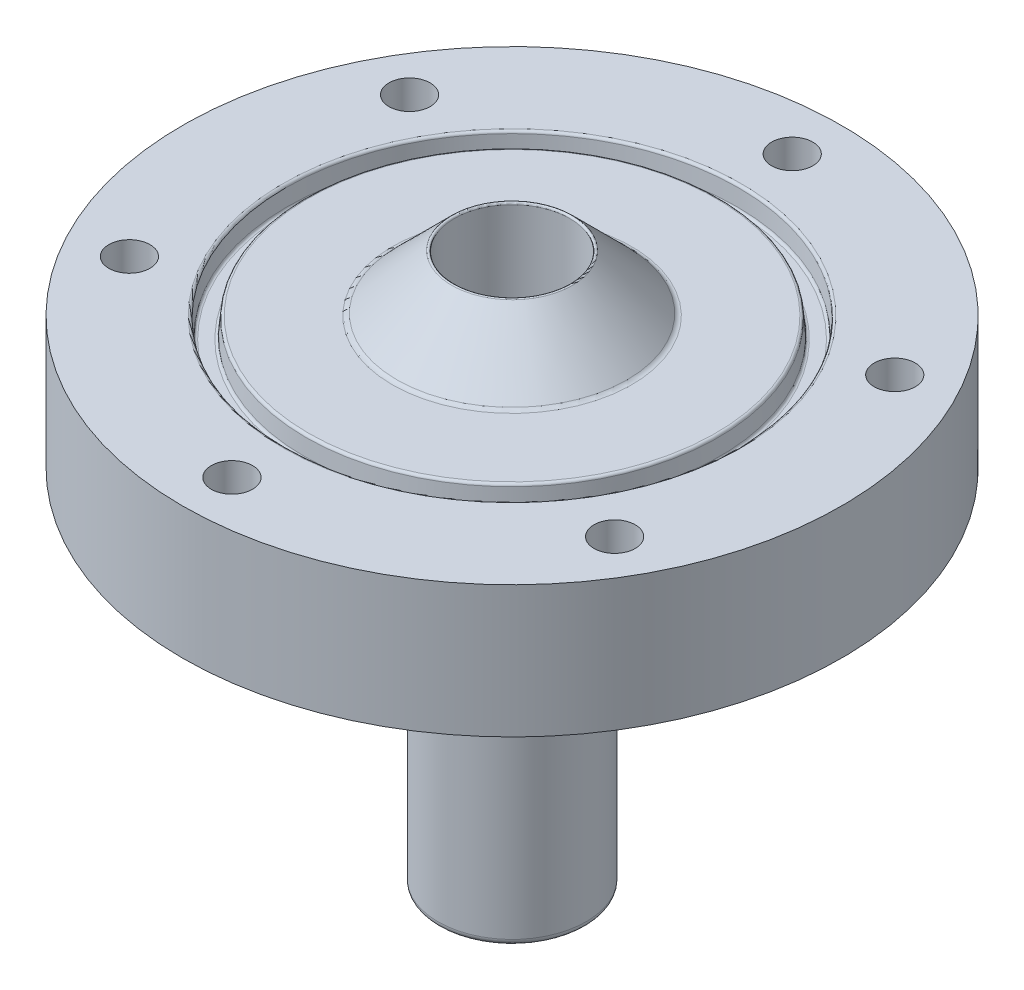
from build123d import *

# Parameters (mm, degrees)
SKETCH3_R          = 17.4625
SKETCH3_R_2        = 15.875
CUT_EXTRUDE1_DEPTH = 1.5875
CUT_EXTRUDE1_TAPER = 5
FILLET2_R          = 0.2032
CUT_EXTRUDE3_REACH = 40.1
SKETCH4_R          = 1.5875
FILLET3_R          = 0.508
FILLET4_R          = 0.127


with BuildPart() as part:
    # Sketch2 → Revolve1 (revolve)
    with BuildSketch(Plane.XY):
        Polygon((-25.4, -0.635), (-5.715, -0.635), (-5.715, -28.575), (-4.445, -28.575), (-4.445, 9.525), (-4.445, 14.097), (-9.016984151, 9.525), (-25.4, 9.525), align=None)
    revolve(axis=Axis((0, 31.121753961, 0), (0, -1, 0)))

    # Sketch3 → Cut-Extrude1 (cut)
    with BuildSketch(Plane(origin=(0, 9.525, 0), x_dir=(1, 0, 0), z_dir=(0, 1, 0))):
        Circle(SKETCH3_R)
        Circle(SKETCH3_R_2, mode=Mode.SUBTRACT)
    extrude(amount=-CUT_EXTRUDE1_DEPTH, taper=CUT_EXTRUDE1_TAPER, mode=Mode.SUBTRACT)

    # Fillet2
    fillet2_edges = [part.edges().sort_by_distance(p)[0] for p in [
        (-17.323611747, 7.9375, 0),
        (-16.013888253, 7.9375, 0),
        (-17.4625, 9.525, 0),
        (-15.875, 9.525, 0),
    ]]
    fillet(fillet2_edges, radius=FILLET2_R)

    # Sketch4 → Cut-Extrude3 (cut, up to next)
    with BuildSketch(Plane(origin=(0, 9.525, 0), x_dir=(1, 0, 0), z_dir=(0, 1, 0)), mode=Mode.PRIVATE) as cut_extrude3_sk1:
        with Locations((0, 21.59)):
            Circle(SKETCH4_R)
    cut_extrude3_tool1 = extrude(cut_extrude3_sk1.sketch, amount=-CUT_EXTRUDE3_REACH, mode=Mode.PRIVATE) & part.part
    add(cut_extrude3_tool1.solids().sort_by_distance((0, 9.525, -21.59))[0], mode=Mode.SUBTRACT)
    # Sketch4 → Cut-Extrude3 (cut, up to next)
    with BuildSketch(Plane(origin=(0, 9.525, 0), x_dir=(1, 0, 0), z_dir=(0, 1, 0)), mode=Mode.PRIVATE) as cut_extrude3_sk2:
        with Locations((18.697488468, 10.795)):
            Circle(SKETCH4_R)
    cut_extrude3_tool2 = extrude(cut_extrude3_sk2.sketch, amount=-CUT_EXTRUDE3_REACH, mode=Mode.PRIVATE) & part.part
    add(cut_extrude3_tool2.solids().sort_by_distance((18.697488, 9.525, -10.795))[0], mode=Mode.SUBTRACT)
    # Sketch4 → Cut-Extrude3 (cut, up to next)
    with BuildSketch(Plane(origin=(0, 9.525, 0), x_dir=(1, 0, 0), z_dir=(0, 1, 0)), mode=Mode.PRIVATE) as cut_extrude3_sk3:
        with Locations((18.697488468, -10.795)):
            Circle(SKETCH4_R)
    cut_extrude3_tool3 = extrude(cut_extrude3_sk3.sketch, amount=-CUT_EXTRUDE3_REACH, mode=Mode.PRIVATE) & part.part
    add(cut_extrude3_tool3.solids().sort_by_distance((18.697488, 9.525, 10.795))[0], mode=Mode.SUBTRACT)
    # Sketch4 → Cut-Extrude3 (cut, up to next)
    with BuildSketch(Plane(origin=(0, 9.525, 0), x_dir=(1, 0, 0), z_dir=(0, 1, 0)), mode=Mode.PRIVATE) as cut_extrude3_sk4:
        with Locations((0, -21.59)):
            Circle(SKETCH4_R)
    cut_extrude3_tool4 = extrude(cut_extrude3_sk4.sketch, amount=-CUT_EXTRUDE3_REACH, mode=Mode.PRIVATE) & part.part
    add(cut_extrude3_tool4.solids().sort_by_distance((0, 9.525, 21.59))[0], mode=Mode.SUBTRACT)
    # Sketch4 → Cut-Extrude3 (cut, up to next)
    with BuildSketch(Plane(origin=(0, 9.525, 0), x_dir=(1, 0, 0), z_dir=(0, 1, 0)), mode=Mode.PRIVATE) as cut_extrude3_sk5:
        with Locations((-18.697488468, -10.795)):
            Circle(SKETCH4_R)
    cut_extrude3_tool5 = extrude(cut_extrude3_sk5.sketch, amount=-CUT_EXTRUDE3_REACH, mode=Mode.PRIVATE) & part.part
    add(cut_extrude3_tool5.solids().sort_by_distance((-18.697488, 9.525, 10.795))[0], mode=Mode.SUBTRACT)
    # Sketch4 → Cut-Extrude3 (cut, up to next)
    with BuildSketch(Plane(origin=(0, 9.525, 0), x_dir=(1, 0, 0), z_dir=(0, 1, 0)), mode=Mode.PRIVATE) as cut_extrude3_sk6:
        with Locations((-18.697488468, 10.795)):
            Circle(SKETCH4_R)
    cut_extrude3_tool6 = extrude(cut_extrude3_sk6.sketch, amount=-CUT_EXTRUDE3_REACH, mode=Mode.PRIVATE) & part.part
    add(cut_extrude3_tool6.solids().sort_by_distance((-18.697488, 9.525, -10.795))[0], mode=Mode.SUBTRACT)

    # Fillet3
    fillet3_edges = [part.edges().sort_by_distance(p)[0] for p in [
        (5.715, -0.635, 0),
        (9.016984151, 9.525, 0),
        (5.715, -28.575, 0),
    ]]
    fillet(fillet3_edges, radius=FILLET3_R)

    # Fillet4
    fillet4_edges = [part.edges().sort_by_distance(p)[0] for p in [
        (4.445, 14.097, 0),
    ]]
    fillet(fillet4_edges, radius=FILLET4_R)


solid = part.part
